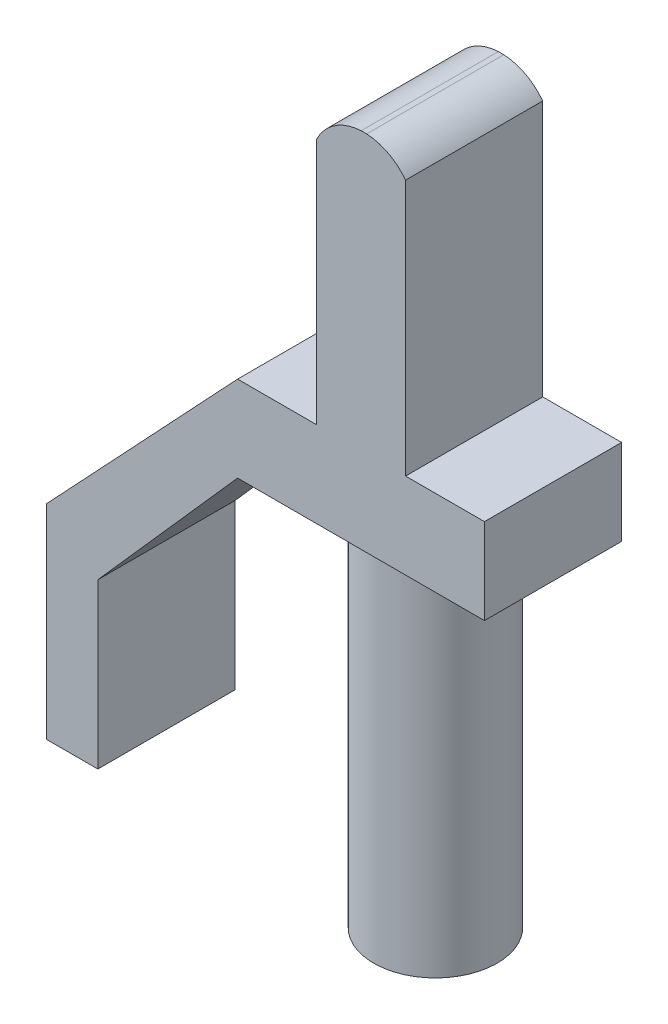
from build123d import *

# Parameters (mm, degrees)
BOSS_EXTRUDE1_DEPTH = 4
SKETCH_1_W          = 7.2
SKETCH_1_H          = 2.5
EXTRUDE_1_DEPTH     = 4
EXTRUDE_2_DEPTH     = 4
SKETCH_6_R          = 1.8
EXTRUDE_3_DEPTH     = 10.65


with BuildPart() as part:
    # Sketch1 → Boss-Extrude1 (new body)
    with BuildSketch(Plane.XY):
        with BuildLine():
            Line((-10.408670574, 3.576426588), (-7.808670574, 3.576426588))
            Line((-7.808670574, 3.576426588), (-7.808670574, 11.055036677))
            ThreePointArc((-7.808670574, 11.055036677), (-8.310608651, 11.480313821), (-8.944823261, 11.655168937))
            Line((-8.944823261, 11.655168937), (-9.103917888, 11.655168937))
            ThreePointArc((-9.103917888, 11.655168937), (-9.878044557, 11.396572098), (-10.408670574, 10.776426588))
            Line((-10.408670574, 10.776426588), (-10.408670574, 3.576426588))
        make_face()
    extrude(amount=BOSS_EXTRUDE1_DEPTH)

    # Эскиз1 → Бобышка-Вытянуть1 (add)
    with BuildSketch(Plane.XY.offset(4)):
        with Locations((-9.108670574, 2.329960492)):
            Rectangle(SKETCH_1_W, SKETCH_1_H)
    extrude(amount=-EXTRUDE_1_DEPTH)

    # Эскиз5 → Бобышка-Вытянуть2 (add)
    with BuildSketch(Plane.XY.offset(4)):
        Polygon((-12.708670574, 3.579960492), (-18.284126234, -2.357514059), (-18.284126234, -8.307514059), (-16.784126234, -8.307514059), (-16.784126234, -3.524992463), (-12.708670574, 1.079960492), align=None)
    extrude(amount=-EXTRUDE_2_DEPTH)

    # Эскиз6 → Бобышка-Вытянуть3 (add)
    with BuildSketch(Plane.XZ.offset(-1.079960492)):
        with Locations((-9.118354015, 1.82)):
            Circle(SKETCH_6_R)
    extrude(amount=EXTRUDE_3_DEPTH)


solid = part.part
